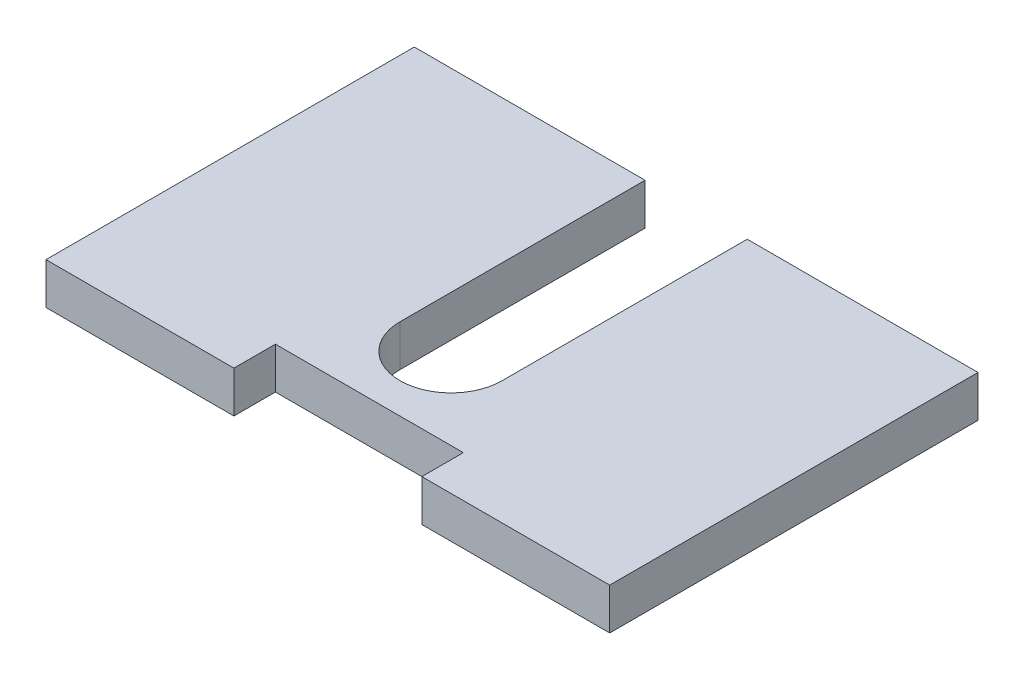
from build123d import *

# Parameters (mm, degrees)
SKETCH1_W           = 69
SKETCH1_H           = 40
BOSS_EXTRUDE1_DEPTH = 5.08
SKETCH2_W           = 23
SKETCH2_H           = 5.08
BOSS_EXTRUDE2_DEPTH = 5.08
CUT_EXTRUDE4_DEPTH  = 5.08


with BuildPart() as part:
    # Sketch1 → Boss-Extrude1 (new body)
    with BuildSketch(Plane(origin=(0, 0, 0), x_dir=(1, 0, 0), z_dir=(0, 1, 0))):
        with Locations((-34.5, 20)):
            Rectangle(SKETCH1_W, SKETCH1_H)
    extrude(amount=BOSS_EXTRUDE1_DEPTH)

    # Sketch2 → Boss-Extrude2 (add)
    with BuildSketch(Plane.XY):
        with Locations((-57.5, 2.54)):
            Rectangle(SKETCH2_W, SKETCH2_H)
        with Locations((-11.5, 2.54)):
            Rectangle(SKETCH2_W, SKETCH2_H)
    extrude(amount=BOSS_EXTRUDE2_DEPTH)

    # Sketch7 → Cut-Extrude4 (cut)
    with BuildSketch(Plane(origin=(0, 5.08, 0), x_dir=(1, 0, 0), z_dir=(0, 1, 0))):
        with BuildLine():
            ThreePointArc((-28.25, 10), (-34.5, 16.25), (-40.75, 10))
            Line((-40.75, 10), (-28.25, 10))
        make_face()
        with BuildLine():
            Line((-28.25, 10), (-40.75, 10))
            ThreePointArc((-40.75, 10), (-34.5, 3.75), (-28.25, 10))
        make_face()
        with BuildLine():
            Line((-40.75, 40), (-40.75, 10))
            ThreePointArc((-40.75, 10), (-34.5, 16.25), (-28.25, 10))
            Line((-28.25, 10), (-28.25, 40))
            Line((-28.25, 40), (-40.75, 40))
        make_face()
    extrude(amount=-CUT_EXTRUDE4_DEPTH, mode=Mode.SUBTRACT)


solid = part.part
